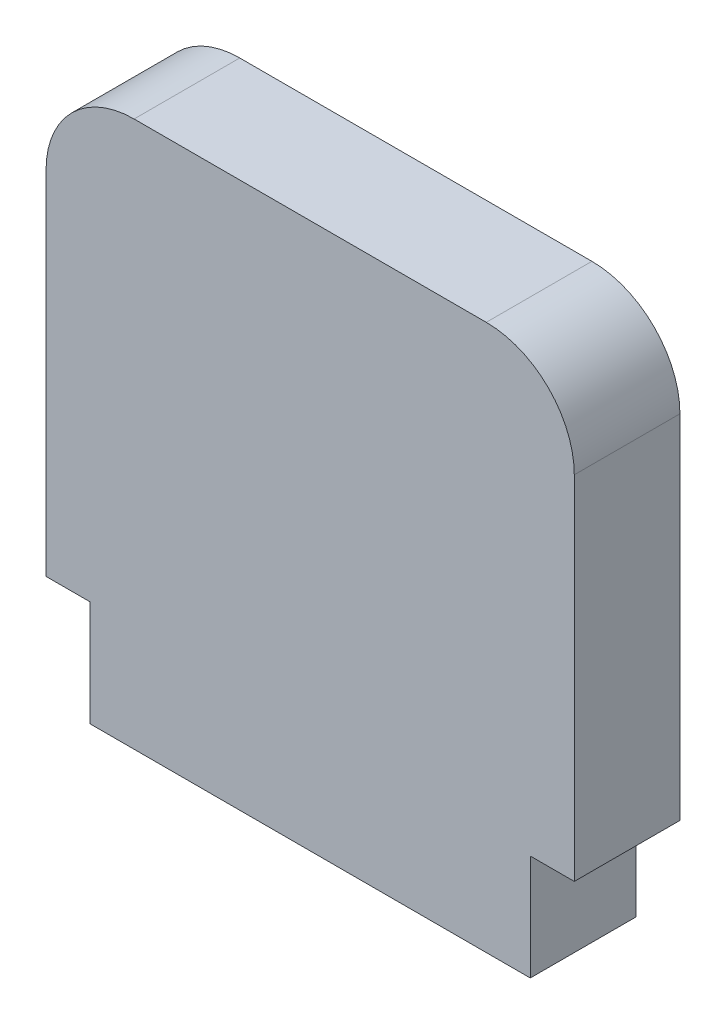
from build123d import *

# Parameters (mm, degrees)
ESBO_O1_W                = 30
ESBO_O1_H                = 25
ESBO_O1_W_2              = 25
ESBO_O1_H_2              = 6
RESSALTO_EXTRUS_O1_DEPTH = 6
FILETE1_R                = 5


with BuildPart() as part:
    # Esboço1 → Ressalto-extrusão1 (new body)
    with BuildSketch(Plane.XY):
        Rectangle(ESBO_O1_W, ESBO_O1_H)
        with Locations((0, -15.5)):
            Rectangle(ESBO_O1_W_2, ESBO_O1_H_2)
    extrude(amount=RESSALTO_EXTRUS_O1_DEPTH)

    # Filete1
    filete1_edges = [part.edges().sort_by_distance(p)[0] for p in [
        (-15, 12.5, 3),
        (15, 12.5, 3),
    ]]
    fillet(filete1_edges, radius=FILETE1_R)


solid = part.part
